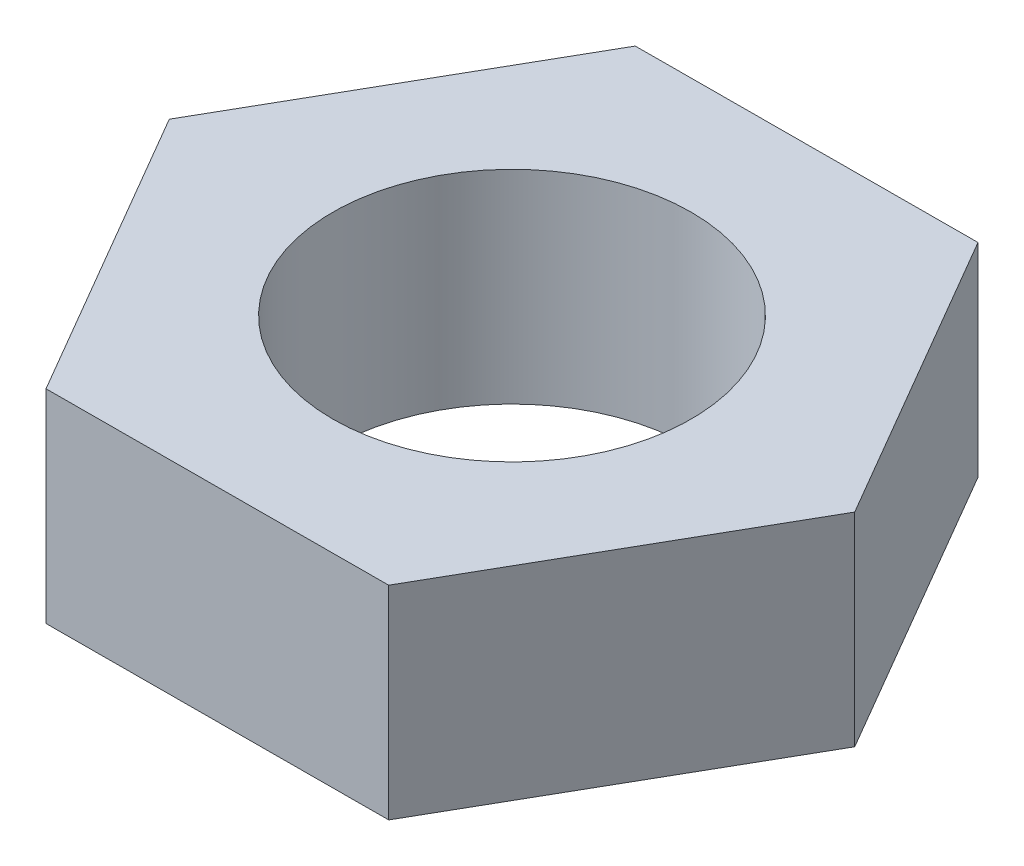
from build123d import *

# Parameters (mm, degrees)
BOSS_EXTRUDE1_DEPTH = 9.22
SKETCH2_R           = 8.128
CUT_EXTRUDE1_DEPTH  = 10.22


with BuildPart() as part:
    # Sketch1 → Boss-Extrude1 (new body)
    with BuildSketch(Plane(origin=(0, 0, 0), x_dir=(1, 0, 0), z_dir=(0, 1, 0))):
        Polygon((7.693812666, 13.439455367), (-7.792003428, 13.382764905), (-15.485816094, -0.056690463), (-7.693812666, -13.439455367), (7.792003428, -13.382764905), (15.485816094, 0.056690463), align=None)
    extrude(amount=BOSS_EXTRUDE1_DEPTH)

    # Sketch2 → Cut-Extrude1 (cut, through all)
    with BuildSketch(Plane(origin=(0, 9.22, 0), x_dir=(1, 0, 0), z_dir=(0, 1, 0))):
        Circle(SKETCH2_R)
    extrude(amount=-CUT_EXTRUDE1_DEPTH, mode=Mode.SUBTRACT)


solid = part.part
